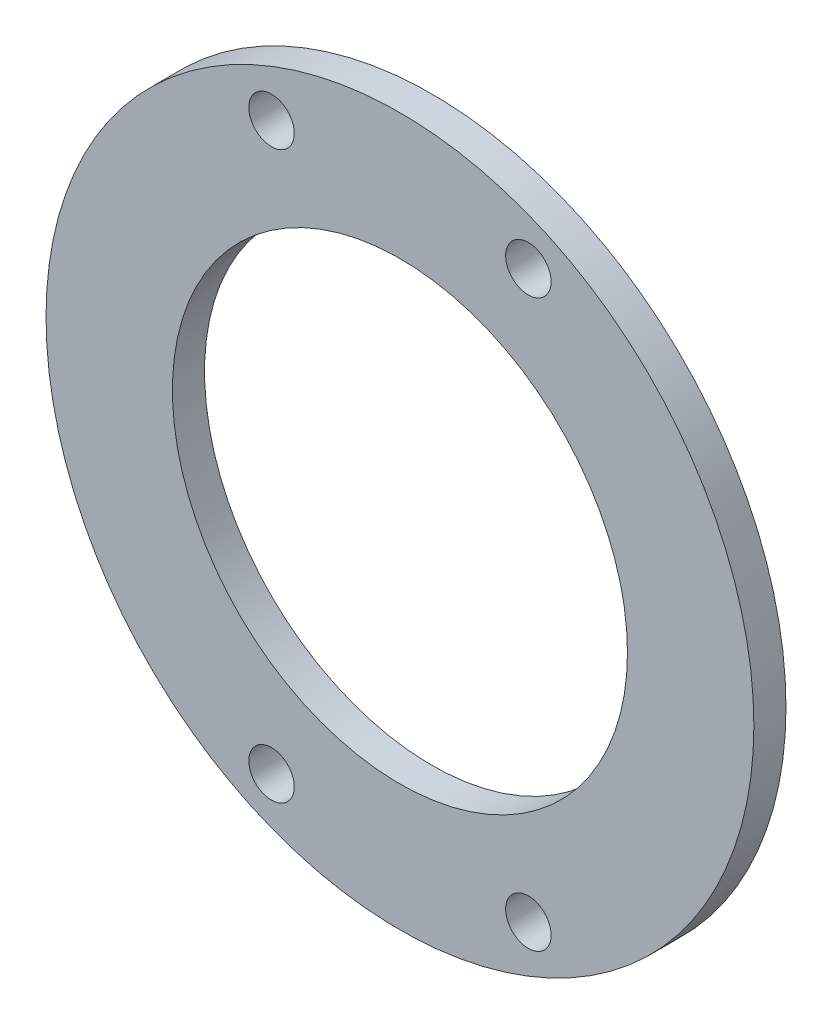
from build123d import *

# Parameters (mm, degrees)
SKETCH2_R            = 35
SKETCH2_R_2          = 22.5
BOSS_EXTRUDE1_DEPTH  = 3.175
M4_CLEARANCE_HOLE1_D = 4.5


with BuildPart() as part:
    # Sketch2 → Boss-Extrude1 (new body)
    with BuildSketch(Plane.XY):
        Circle(SKETCH2_R)
        Circle(SKETCH2_R_2, mode=Mode.SUBTRACT)
    extrude(amount=BOSS_EXTRUDE1_DEPTH)

    # M4 Clearance Hole1 (through all)
    with Locations(Plane(origin=(0, 0, 0), x_dir=(-1, 0, 0), z_dir=(0, 0, -1))):
        with Locations((-12.7, 27.9796875), (12.7, 27.9796875), (12.7, -27.9796875), (-12.7, -27.9796875)):
            Hole(M4_CLEARANCE_HOLE1_D / 2)


solid = part.part
